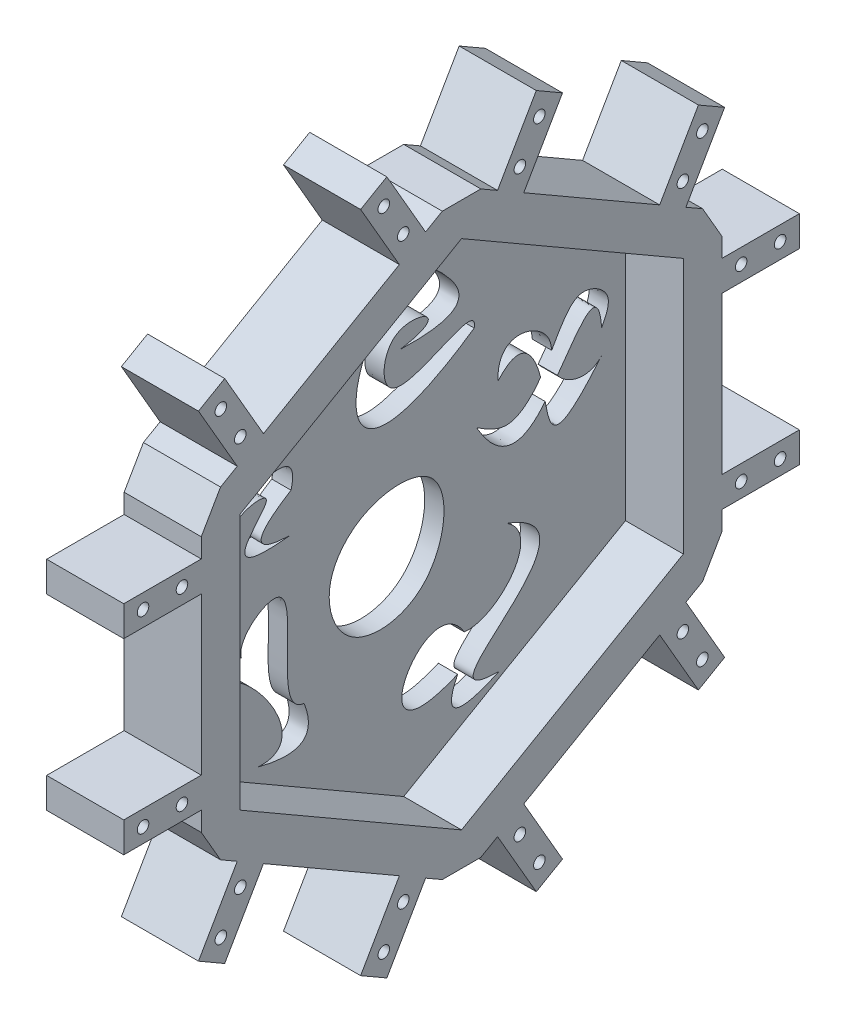
from build123d import *

# Parameters (mm, degrees)
SKETCH_4_R          = 1.5
EXTRUDE_2_DEPTH     = 20
CUT_EXTRUDE_3_DEPTH = 15
CUT_EXTRUDE_7_REACH = 128.466


with BuildPart() as part:
    # 草图4 → 凸台-拉伸2 (new body)
    with BuildSketch(Plane(origin=(0, 0, 0), x_dir=(0, 0, -1), z_dir=(1, 0, 0))):
        Polygon((-67.504086811, 20.35), (-67.504086811, -20.35), (-87.604086811, -20.35), (-87.604086811, -28.2), (-67.504086811, -28.2), (-67.504086811, -33.2), (-62.504086811, -41.860254038), (-58.173959792, -44.360254038), (-68.223959792, -61.767364654), (-61.425660373, -65.692364654), (-51.375660373, -48.285254038), (-16.128426439, -68.635254038), (-26.178426439, -86.042364654), (-19.380127019, -89.967364654), (-9.330127019, -72.560254038), (-5, -75.060254038), (5, -75.060254038), (9.330127019, -72.560254038), (19.380127019, -89.967364654), (26.178426439, -86.042364654), (16.128426439, -68.635254038), (51.375660373, -48.285254038), (61.425660373, -65.692364654), (68.223959792, -61.767364654), (58.173959792, -44.360254038), (62.504086811, -41.860254038), (67.504086811, -33.2), (67.504086811, -28.2), (87.604086811, -28.2), (87.604086811, -20.35), (67.504086811, -20.35), (67.504086811, 20.35), (87.604086811, 20.35), (87.604086811, 28.2), (67.504086811, 28.2), (67.504086811, 33.2), (62.504086811, 41.860254038), (58.173959792, 44.360254038), (68.223959792, 61.767364654), (61.425660373, 65.692364654), (51.375660373, 48.285254038), (16.128426439, 68.635254038), (26.178426439, 86.042364654), (19.380127019, 89.967364654), (9.330127019, 72.560254038), (5, 75.060254038), (-5, 75.060254038), (-9.330127019, 72.560254038), (-19.380127019, 89.967364654), (-26.178426439, 86.042364654), (-16.128426439, 68.635254038), (-51.375660373, 48.285254038), (-61.425660373, 65.692364654), (-68.223959792, 61.767364654), (-58.173959792, 44.360254038), (-62.504086811, 41.860254038), (-67.504086811, 33.2), (-67.504086811, 28.2), (-87.604086811, 28.2), (-87.604086811, 20.35), align=None)
        with Locations((-62.433063258, -59.337237635)):
            Circle(SKETCH_4_R, mode=Mode.SUBTRACT)
        with Locations((-57.383063258, -50.590381057)):
            Circle(SKETCH_4_R, mode=Mode.SUBTRACT)
        with Locations((-20.171023553, -83.737237635)):
            Circle(SKETCH_4_R, mode=Mode.SUBTRACT)
        with Locations((-15.121023553, -74.990381057)):
            Circle(SKETCH_4_R, mode=Mode.SUBTRACT)
        with Locations((-82.604086811, -24.4)):
            Circle(SKETCH_4_R, mode=Mode.SUBTRACT)
        with Locations((-72.504086811, -24.4)):
            Circle(SKETCH_4_R, mode=Mode.SUBTRACT)
        with Locations((20.171023553, -83.737237635)):
            Circle(SKETCH_4_R, mode=Mode.SUBTRACT)
        with Locations((15.121023553, -74.990381057)):
            Circle(SKETCH_4_R, mode=Mode.SUBTRACT)
        with Locations((62.433063258, -59.337237635)):
            Circle(SKETCH_4_R, mode=Mode.SUBTRACT)
        with Locations((57.383063258, -50.590381057)):
            Circle(SKETCH_4_R, mode=Mode.SUBTRACT)
        with Locations((-82.604086811, 24.4)):
            Circle(SKETCH_4_R, mode=Mode.SUBTRACT)
        with Locations((-72.504086811, 24.4)):
            Circle(SKETCH_4_R, mode=Mode.SUBTRACT)
        with Locations((-57.383063258, 50.590381057)):
            Circle(SKETCH_4_R, mode=Mode.SUBTRACT)
        with Locations((-62.433063258, 59.337237635)):
            Circle(SKETCH_4_R, mode=Mode.SUBTRACT)
        with Locations((-15.121023553, 74.990381057)):
            Circle(SKETCH_4_R, mode=Mode.SUBTRACT)
        with Locations((-20.171023553, 83.737237635)):
            Circle(SKETCH_4_R, mode=Mode.SUBTRACT)
        with Locations((72.504086811, 24.4)):
            Circle(SKETCH_4_R, mode=Mode.SUBTRACT)
        with Locations((82.604086811, 24.4)):
            Circle(SKETCH_4_R, mode=Mode.SUBTRACT)
        with Locations((15.121023553, 74.990381057)):
            Circle(SKETCH_4_R, mode=Mode.SUBTRACT)
        with Locations((20.171023553, 83.737237635)):
            Circle(SKETCH_4_R, mode=Mode.SUBTRACT)
        with Locations((57.383063258, 50.590381057)):
            Circle(SKETCH_4_R, mode=Mode.SUBTRACT)
        with Locations((62.433063258, 59.337237635)):
            Circle(SKETCH_4_R, mode=Mode.SUBTRACT)
        with Locations((72.504086811, -24.4)):
            Circle(SKETCH_4_R, mode=Mode.SUBTRACT)
        with Locations((82.604086811, -24.4)):
            Circle(SKETCH_4_R, mode=Mode.SUBTRACT)
    extrude(amount=EXTRUDE_2_DEPTH)

    # 草图5 → 切除-拉伸3 (cut)
    with BuildSketch(Plane(origin=(20, 0, 0), x_dir=(0, 0, -1), z_dir=(1, 0, 0))):
        Polygon((57.504086811, 33.2), (57.504086811, 23.213641106), (57.504086811, -33.2), (48.855646318, -38.193179447), (0, -66.4), (-8.648440493, -61.406820553), (-57.504086811, -33.2), (-57.504086811, -23.213641106), (-57.504086811, 33.2), (-48.855646318, 38.193179447), (0, 66.4), (8.648440493, 61.406820553), align=None)
    extrude(amount=-CUT_EXTRUDE_3_DEPTH, mode=Mode.SUBTRACT)

    # 草图7 → 切除-拉伸7 (cut, up to next)
    with BuildSketch(Plane(origin=(5, 0, 0), x_dir=(0, 0, -1), z_dir=(1, 0, 0)), mode=Mode.PRIVATE) as cut_extrude_7_sk1:
        with BuildLine():
            add(Edge.make_bspline(
                [(-8.893986295, 2.692778676), (-14.61694185, 0.243700307), (-22.182814171, -9.047407971), (-14.99693634, -27.730664076), (9.706899781, -25.656757612), (13.721652859, 4.923038134), (-3.414571088, 5.037636527), (-8.893986295, 2.692778676)],
                knots=[0, 0, 0, 0, 0.189535406, 0.348179954, 0.552570886, 0.818530272, 1, 1, 1, 1], degree=3))
        make_face()
    cut_extrude_7_tool1 = extrude(cut_extrude_7_sk1.sketch, amount=-CUT_EXTRUDE_7_REACH, mode=Mode.PRIVATE) & part.part
    # 草图7 → 切除-拉伸7 (cut, up to next)
    with BuildSketch(Plane(origin=(5, 0, 0), x_dir=(0, 0, -1), z_dir=(1, 0, 0)), mode=Mode.PRIVATE) as cut_extrude_7_sk2:
        with BuildLine():
            add(Edge.make_bspline(
                [(13.976235055, -45.937224519), (7.954781962, -58.299906387), (24.711373395, -50.666044569)],
                knots=[0, 0, 0, 1, 1, 1], degree=2))
            add(Edge.make_bspline(
                [(24.711373395, -50.666044569), (-0.511966557, -50.302977798), (55.66090331, -28.926565956), (26.780232167, -18.450957975)],
                knots=[0, 0, 0, 0, 1, 1, 1, 1], degree=3))
            add(Edge.make_bspline(
                [(26.780232167, -18.450957975), (36.535527731, -24.716133423), (24.135952636, -38.463351043), (15.697060173, -37.27213305)],
                knots=[0, 0, 0, 0, 1, 1, 1, 1], degree=3))
            add(Edge.make_bspline(
                [(15.697060173, -37.27213305), (5.802578466, -21.049601548), (-14.300143555, -57.964430966), (13.976235055, -45.937224519)],
                knots=[0, 0, 0, 0, 1, 1, 1, 1], degree=3))
        make_face()
    cut_extrude_7_tool2 = extrude(cut_extrude_7_sk2.sketch, amount=-CUT_EXTRUDE_7_REACH, mode=Mode.PRIVATE) & part.part
    # 草图7 → 切除-拉伸7 (cut, up to next)
    with BuildSketch(Plane(origin=(5, 0, 0), x_dir=(0, 0, -1), z_dir=(1, 0, 0)), mode=Mode.PRIVATE) as cut_extrude_7_sk3:
        with BuildLine():
            add(Edge.make_bspline(
                [(36.669946227, 3.996042307), (27.280913551, -7.879533661), (18.887781577, 6.976405821)],
                knots=[0, 0, 0, 1, 1, 1], degree=2))
            add(Edge.make_bspline(
                [(18.887781577, 6.976405821), (21.799589854, 5.147298415), (27.101474772, 1.816819193), (32.883937773, 6.556929106), (35.002377705, 9.262226772), (35.500303429, 9.960582121)],
                knots=[0, 0, 0, 0, 0.179960082, 0.327675298, 0.377932261, 0.377932261, 0.377932261, 0.377932261], degree=3))
            add(Edge.make_bspline(
                [(24.44749732, 14.698233242), (29.692370528, 20.639556649), (33.528003658, 16.616197787), (35.223886393, 11.055460767), (35.500303429, 9.960582121)],
                knots=[0, 0, 0, 0, 0.291030202, 0.361024407, 0.361024407, 0.361024407, 0.361024407], degree=3))
            add(Edge.make_bspline(
                [(24.44749732, 14.698233242), (23.990935594, 25.9811784), (37.21943939, 22.459203648), (38.291230003, 15.446845426), (38.361526382, 14.625725061)],
                knots=[0, 0, 0, 0, 0.465592268, 0.526149345, 0.526149345, 0.526149345, 0.526149345], degree=3))
            add(Edge.make_bspline(
                [(38.361526382, 14.625725061), (39.347778592, 16.380221568), (41.245710308, 19.802103538), (46.046793646, 25.533528572), (54.895840465, 20.204564982), (52.424819508, 15.333046159), (51.319456746, 13.153867758)],
                knots=[0.486603389, 0.486603389, 0.486603389, 0.486603389, 0.606455269, 0.716129494, 0.873016097, 1, 1, 1, 1], degree=3))
            add(Edge.make_bspline(
                [(51.319456746, 13.153867758), (50.611199233, 24.416323812), (45.810135546, 16.584461031), (39.854575223, 8.266809889)],
                knots=[0, 0, 0, 0, 0.460407322, 0.460407322, 0.460407322, 0.460407322], degree=3))
            add(Edge.make_bspline(
                [(39.854575223, 8.266809889), (42.352866562, 4.877895141), (48.08492616, 3.284348169), (51.319456746, 6.976405821)],
                knots=[0.690631072, 0.690631072, 0.690631072, 0.690631072, 1, 1, 1, 1], degree=3))
            add(Edge.make_bspline(
                [(36.669946227, 3.996042307), (37.971815538, -3.419159562), (39.236414277, -7.714814724), (51.319456746, 6.976405821)],
                knots=[0.489946893, 0.489946893, 0.489946893, 0.489946893, 1, 1, 1, 1], degree=3))
        make_face()
    cut_extrude_7_tool3 = extrude(cut_extrude_7_sk3.sketch, amount=-CUT_EXTRUDE_7_REACH, mode=Mode.PRIVATE) & part.part
    # 草图7 → 切除-拉伸7 (cut, up to next)
    with BuildSketch(Plane(origin=(5, 0, 0), x_dir=(0, 0, -1), z_dir=(1, 0, 0)), mode=Mode.PRIVATE) as cut_extrude_7_sk4:
        with BuildLine():
            add(Edge.make_bspline(
                [(-25.844314699, -32.536658273), (-20.886759173, -45.325286318), (-37.961915978, -40.860536484)],
                knots=[0, 0, 0, 1, 1, 1], degree=2))
            add(Edge.make_bspline(
                [(-49.085372881, -23.942863648), (-51.219071108, -3.367640262), (-17.958195198, -42.267155682), (-37.961915978, -40.860536484)],
                knots=[0, 0, 0, 0, 1, 1, 1, 1], degree=3))
            add(Edge.make_bspline(
                [(-49.085372881, -23.942863648), (-58.519571192, -17.614321731), (-47.221503315, -10.847332361), (-42.107229629, -14.268636016)],
                knots=[0, 0, 0, 0, 1, 1, 1, 1], degree=3))
            add(Edge.make_bspline(
                [(-42.107229629, -14.268636016), (-43.370008388, -9.820967302), (-22.119191477, 5.961119183), (-34.580346295, -31.722468877), (-25.844314699, -32.536658273)],
                knots=[0, 0, 0, 0, 0.328149749, 1, 1, 1, 1], degree=3))
        make_face()
    cut_extrude_7_tool4 = extrude(cut_extrude_7_sk4.sketch, amount=-CUT_EXTRUDE_7_REACH, mode=Mode.PRIVATE) & part.part
    # 草图7 → 切除-拉伸7 (cut, up to next)
    with BuildSketch(Plane(origin=(5, 0, 0), x_dir=(0, 0, -1), z_dir=(1, 0, 0)), mode=Mode.PRIVATE) as cut_extrude_7_sk5:
        with BuildLine():
            add(Edge.make_bspline(
                [(-29.229237079, 17.014781468), (-44.510108953, 7.53988469), (-29.634861211, 6.976405821)],
                knots=[0, 0, 0, 1, 1, 1], degree=2))
            add(Edge.make_bspline(
                [(-53.388523085, 13.153867758), (-48.66474559, 6.382779324), (-47.579280248, 18.731683769), (-28.100053083, 19.675858063), (-51.909395903, 4.470935223), (-29.634861211, 6.976405821)],
                knots=[0, 0, 0, 0, 0.436573171, 0.602262861, 1, 1, 1, 1], degree=3))
            add(Edge.make_bspline(
                [(-43.195710889, 34.311674892), (-25.764972329, 36.549376375), (-53.388523085, 13.153867758)],
                knots=[0, 0, 0, 1, 1, 1], degree=2))
            add(Edge.make_bspline(
                [(-43.195710889, 34.311674892), (-42.370900894, 39.981113063), (-18.472069101, 38.918235808), (-37.620414204, 23.201598564), (-37.790431695, 22.265624115)],
                knots=[0, 0, 0, 0, 0.500982596, 1, 1, 1, 1], degree=3))
            add(Edge.make_bspline(
                [(-37.790431695, 22.265624115), (-26.838968202, 25.959820322), (-29.229237079, 17.014781468)],
                knots=[0, 0, 0, 1, 1, 1], degree=2))
        make_face()
    cut_extrude_7_tool5 = extrude(cut_extrude_7_sk5.sketch, amount=-CUT_EXTRUDE_7_REACH, mode=Mode.PRIVATE) & part.part
    # 草图7 → 切除-拉伸7 (cut, up to next)
    with BuildSketch(Plane(origin=(5, 0, 0), x_dir=(0, 0, -1), z_dir=(1, 0, 0)), mode=Mode.PRIVATE) as cut_extrude_7_sk6:
        with BuildLine():
            add(Edge.make_bspline(
                [(-1.023813613, 34.458489315), (21.401328797, 33.641793974), (11.022237164, 44.960174608)],
                knots=[0, 0, 0, 1, 1, 1], degree=2))
            add(Edge.make_bspline(
                [(11.022237164, 44.960174608), (-7.154868825, 68.009496034), (-34.263712642, -6.4332349), (18.28075494, 29.670956314)],
                knots=[0, 0, 0, 0, 1, 1, 1, 1], degree=3))
            add(Edge.make_bspline(
                [(-1.023813613, 34.458489315), (13.649787219, 36.757052055), (-4.909228956, 45.079566383), (-6.981612701, 16.019949353), (19.579363007, 36.940901182), (18.28075494, 29.670956314)],
                knots=[0, 0, 0, 0, 0.322419343, 0.55108065, 1, 1, 1, 1], degree=3))
        make_face()
    cut_extrude_7_tool6 = extrude(cut_extrude_7_sk6.sketch, amount=-CUT_EXTRUDE_7_REACH, mode=Mode.PRIVATE) & part.part
    add(cut_extrude_7_tool1.solids().sort_by_distance((5, -10.651687, 4.26835))[0], mode=Mode.SUBTRACT)
    add(cut_extrude_7_tool2.solids().sort_by_distance((5, -39.587091, -16.128473))[0], mode=Mode.SUBTRACT)
    add(cut_extrude_7_tool3.solids().sort_by_distance((5, 10.507813, -37.634898))[0], mode=Mode.SUBTRACT)
    add(cut_extrude_7_tool4.solids().sort_by_distance((5, -21.159157, 35.933642))[0], mode=Mode.SUBTRACT)
    add(cut_extrude_7_tool5.solids().sort_by_distance((5, 22.654443, 37.761394))[0], mode=Mode.SUBTRACT)
    add(cut_extrude_7_tool6.solids().sort_by_distance((5, 35.892548, -10.861089))[0], mode=Mode.SUBTRACT)


solid = part.part
